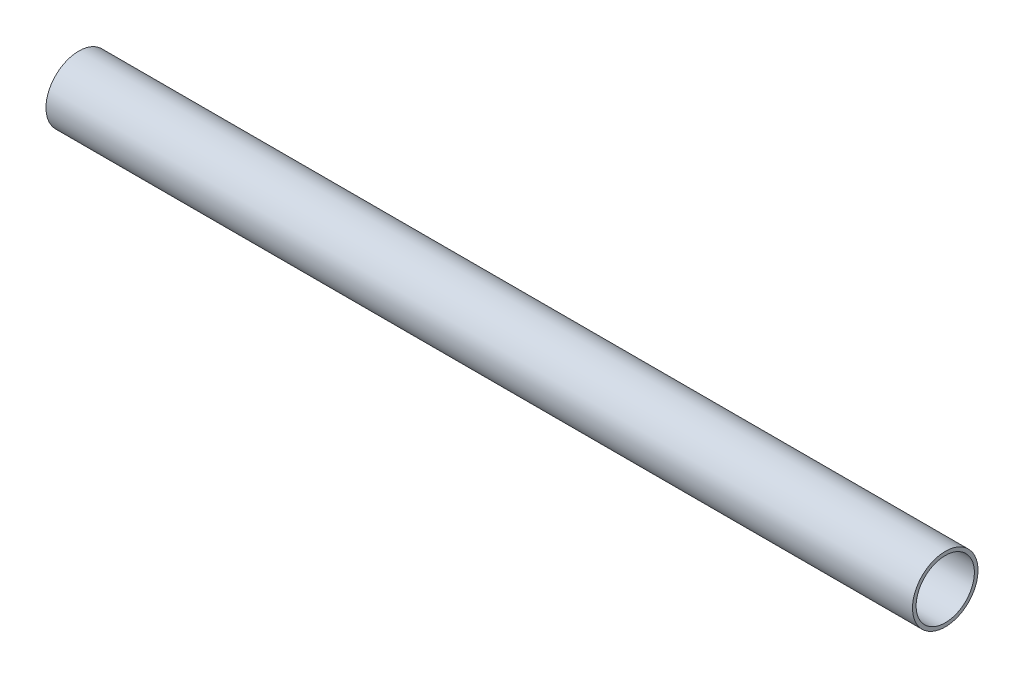
from build123d import *

# Parameters (mm, degrees)
SKETCH_1_R      = 13.5
SKETCH_1_R_2    = 12
EXTRUDE_1_DEPTH = 357


with BuildPart() as part:
    # Эскиз1 → Бобышка-Вытянуть1 (new body)
    with BuildSketch(Plane(origin=(0, 0, 0), x_dir=(0, 0, -1), z_dir=(1, 0, 0))):
        Circle(SKETCH_1_R)
        Circle(SKETCH_1_R_2, mode=Mode.SUBTRACT)
    extrude(amount=EXTRUDE_1_DEPTH)


solid = part.part
